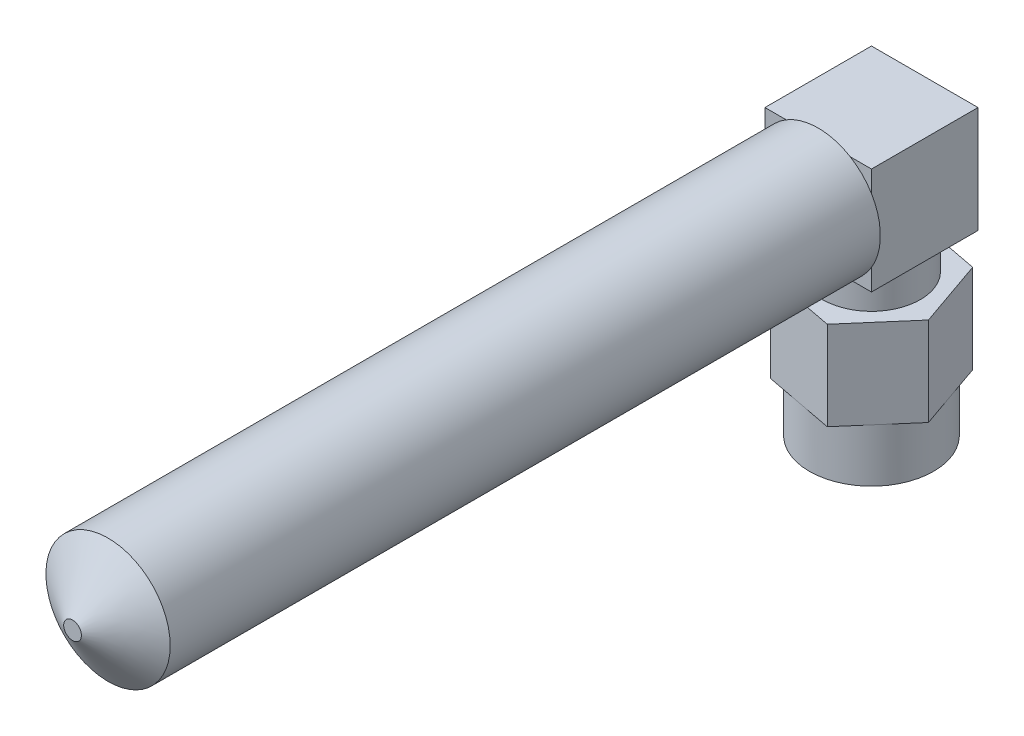
from build123d import *

# Parameters (mm, degrees)
SKETCH_1_R          = 3.5
EXTRUDE_1_DEPTH     = 3
EXTRUDE_2_DEPTH     = 5
SKETCH_3_R          = 2.75
EXTRUDE_3_DEPTH     = 2
SKETCH_4_R          = 2.5
CUT_EXTRUDE_1_DEPTH = 5
SKETCH_5_W          = 6
SKETCH_5_H          = 6
EXTRUDE_4_DEPTH     = 6
SKETCH_6_R          = 3.5
EXTRUDE_7_DEPTH     = 40


with BuildPart() as part:
    # 草图1 → 凸台-拉伸1 (new body)
    with BuildSketch(Plane(origin=(0, 0, 0), x_dir=(1, 0, 0), z_dir=(0, 1, 0))):
        Circle(SKETCH_1_R)
    extrude(amount=EXTRUDE_1_DEPTH)

    # 草图2 → 凸台-拉伸2 (add)
    with BuildSketch(Plane(origin=(0, 3, 0), x_dir=(1, 0, 0), z_dir=(0, 1, 0))):
        Polygon((2.642653224, 3.057730738), (-1.326745885, 3.817470195), (-3.96939911, 0.759739456), (-2.642653224, -3.057730738), (1.326745885, -3.817470195), (3.96939911, -0.759739456), align=None)
    extrude(amount=EXTRUDE_2_DEPTH)

    # 草图3 → 凸台-拉伸3 (add)
    with BuildSketch(Plane(origin=(0, 8, 0), x_dir=(1, 0, 0), z_dir=(0, 1, 0))):
        Circle(SKETCH_3_R)
    extrude(amount=EXTRUDE_3_DEPTH)

    # 草图4 → 切除-拉伸1 (cut)
    with BuildSketch(Plane.XZ):
        Circle(SKETCH_4_R)
    extrude(amount=-CUT_EXTRUDE_1_DEPTH, mode=Mode.SUBTRACT)

    # 草图5 → 凸台-拉伸4 (add)
    with BuildSketch(Plane(origin=(0, 10, 0), x_dir=(1, 0, 0), z_dir=(0, 1, 0))):
        Rectangle(SKETCH_5_W, SKETCH_5_H)
    extrude(amount=EXTRUDE_4_DEPTH)

    # 草图6 → 凸台-拉伸7 (add)
    with BuildSketch(Plane.XY.offset(3)):
        with Locations((0, 13)):
            Circle(SKETCH_6_R)
    extrude(amount=EXTRUDE_7_DEPTH)

    # 草图7 → 旋转1 (revolve)
    with BuildSketch(Plane(origin=(0, 0, 0), x_dir=(0, 0, -1), z_dir=(1, 0, 0))):
        Polygon((-43, 16.5), (-43, 13), (-45, 13), (-45, 13.5), align=None)
    revolve(axis=Axis((0, 13, 43), (0, 0, -1)))


solid = part.part
